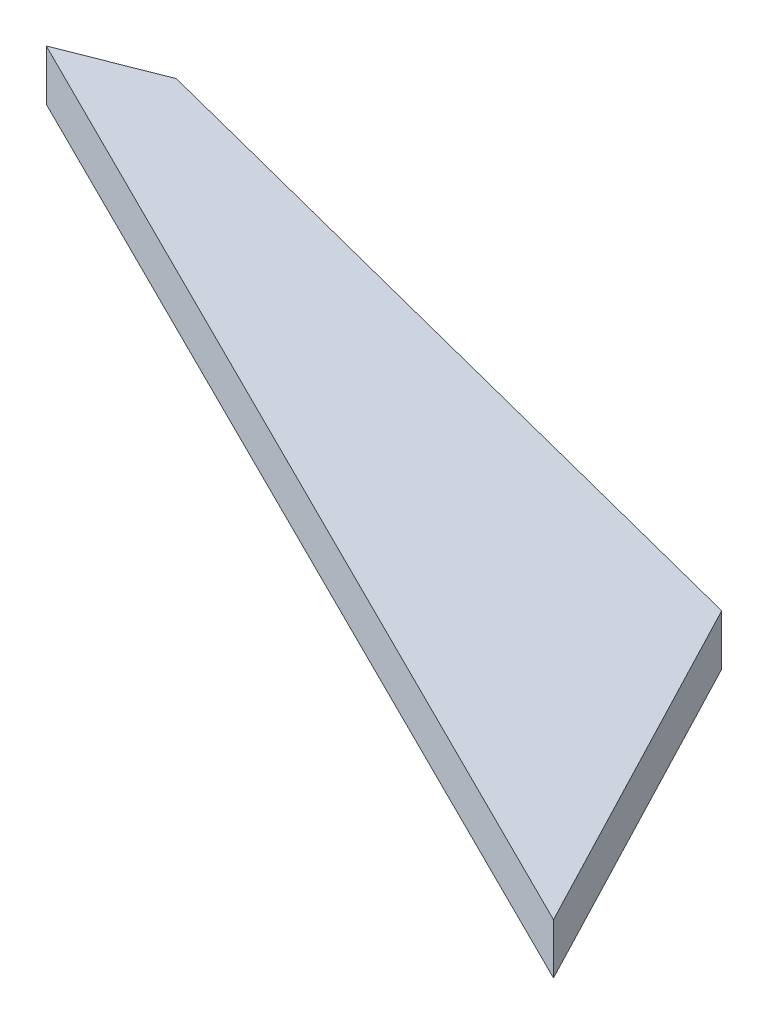
from build123d import *

# Parameters (mm, degrees)
BOSS_EXTRU_1_DEPTH = 2


with BuildPart() as part:
    # Esquisse1 → Boss.-Extru.1 (new body)
    with BuildSketch(Plane(origin=(0, 0, 0), x_dir=(1, 0, 0), z_dir=(0, 1, 0))):
        Polygon((32.74698681, -5.997820849), (3.687489672, 1.457674269), (0, 0), (40.010156038, -19.923441822), align=None)
    extrude(amount=BOSS_EXTRU_1_DEPTH)


solid = part.part
